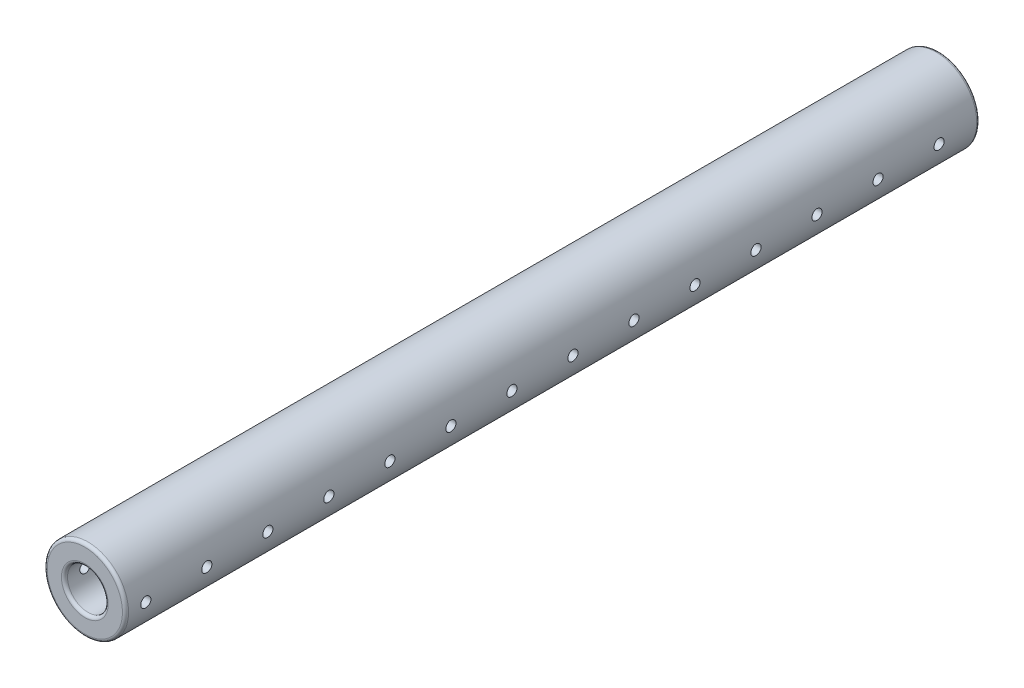
from build123d import *

# Parameters (mm, degrees)
SKETCH1_R               = 20
SKETCH1_R_2             = 10
BOSS_EXTRUDE1_DEPTH     = 420
SKETCH2_R               = 2.5
CUT_EXTRUDE1_DEPTH      = 21
CUT_EXTRUDE1_DEPTH_BACK = 21
FILLET1_R               = 1.5


with BuildPart() as part:
    # Sketch1 → Boss-Extrude1 (new body)
    with BuildSketch(Plane.XY):
        Circle(SKETCH1_R)
        Circle(SKETCH1_R_2, mode=Mode.SUBTRACT)
    extrude(amount=BOSS_EXTRUDE1_DEPTH)

    # Sketch2 → Cut-Extrude1 (cut, two sides)
    with BuildSketch(Plane(origin=(0, 0, 0), x_dir=(0, 0, -1), z_dir=(1, 0, 0))) as cut_extrude1_sk:
        with Locations((-20, 0)):
            Circle(SKETCH2_R)
        with Locations((-50, 0)):
            Circle(SKETCH2_R)
        with Locations((-80, 0)):
            Circle(SKETCH2_R)
        with Locations((-110, 0)):
            Circle(SKETCH2_R)
        with Locations((-140, 0)):
            Circle(SKETCH2_R)
        with Locations((-170, 0)):
            Circle(SKETCH2_R)
        with Locations((-200, 0)):
            Circle(SKETCH2_R)
        with Locations((-230, 0)):
            Circle(SKETCH2_R)
        with Locations((-260, 0)):
            Circle(SKETCH2_R)
        with Locations((-290, 0)):
            Circle(SKETCH2_R)
        with Locations((-320, 0)):
            Circle(SKETCH2_R)
        with Locations((-350, 0)):
            Circle(SKETCH2_R)
        with Locations((-380, 0)):
            Circle(SKETCH2_R)
        with Locations((-410, 0)):
            Circle(SKETCH2_R)
    extrude(amount=CUT_EXTRUDE1_DEPTH, mode=Mode.SUBTRACT)
    extrude(cut_extrude1_sk.sketch, amount=-CUT_EXTRUDE1_DEPTH_BACK, mode=Mode.SUBTRACT)

    # Fillet1
    fillet1_edges = [part.edges().sort_by_distance(p)[0] for p in [
        (-20, 0, 0),
        (-20, 0, 420),
        (-10, 0, 0),
        (-10, 0, 420),
    ]]
    fillet(fillet1_edges, radius=FILLET1_R)


solid = part.part
